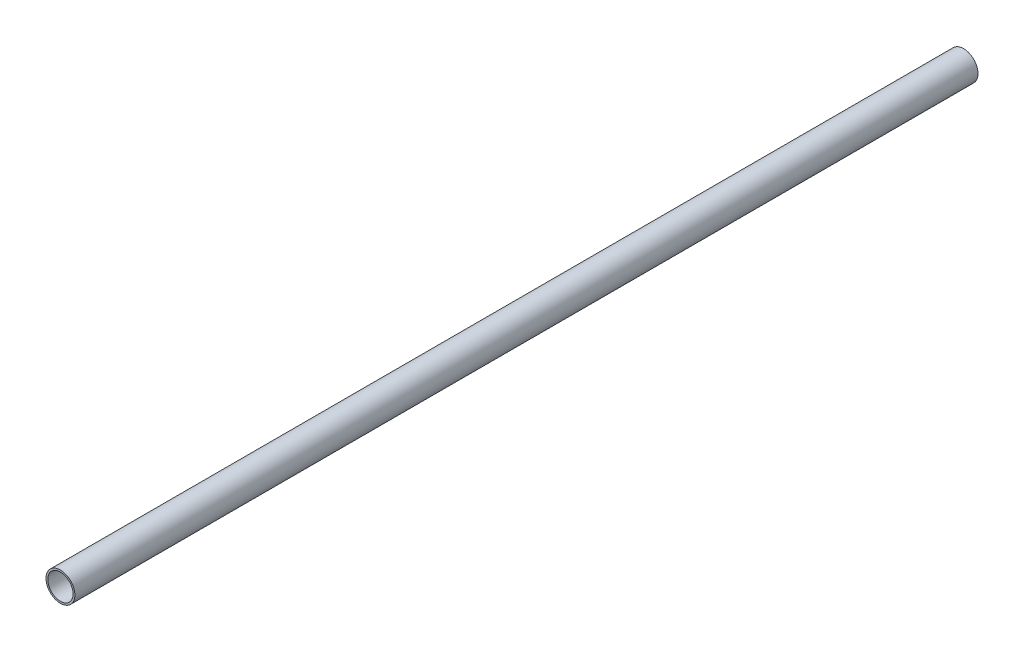
from build123d import *

# Parameters (mm, degrees)
SKETCH_1_R      = 8
SKETCH_1_R_2    = 7
EXTRUDE_1_DEPTH = 250


with BuildPart() as part:
    # Эскиз1 → Бобышка-Вытянуть1 (new body, symmetric)
    with BuildSketch(Plane.XY):
        Circle(SKETCH_1_R)
        Circle(SKETCH_1_R_2, mode=Mode.SUBTRACT)
    extrude(amount=EXTRUDE_1_DEPTH, both=True)


solid = part.part
